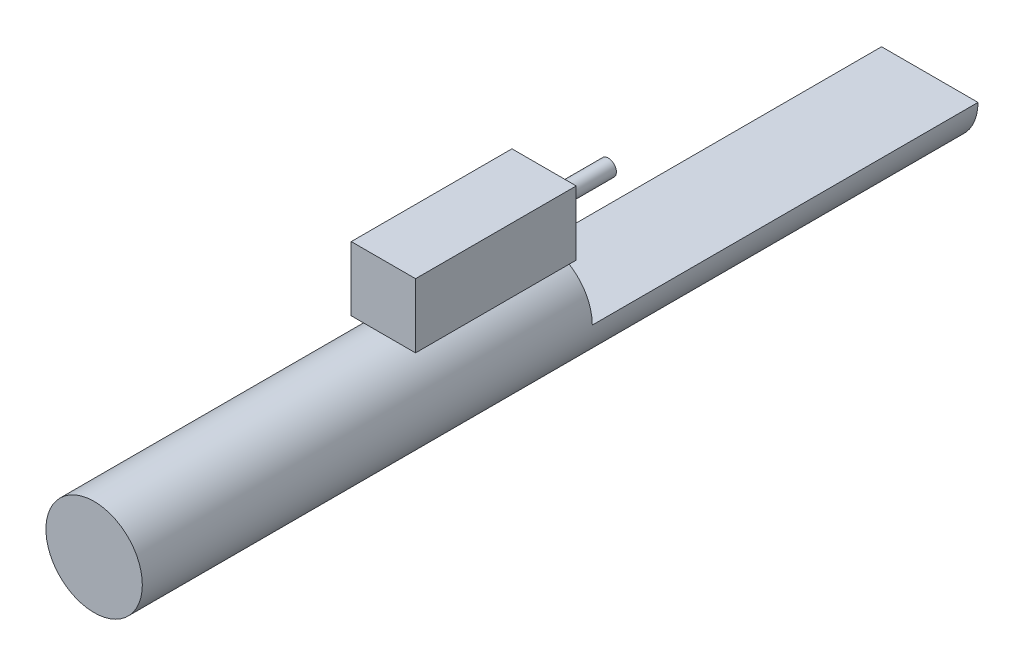
from build123d import *

# Parameters (mm, degrees)
SKETCH_1_R      = 7.5
EXTRUDE_1_DEPTH = 70
EXTRUDE_START   = 60
EXTRUDE_2_DEPTH = 60
SKETCH_4_W      = 10
SKETCH_4_H      = 25
EXTRUDE_3_DEPTH = 10
SKETCH_5_R      = 1.25
EXTRUDE_4_DEPTH = 10


with BuildPart() as part:
    # 草圖1 → 填料-伸長1 (new body)
    with BuildSketch(Plane.XY):
        Circle(SKETCH_1_R)
    extrude(amount=EXTRUDE_1_DEPTH)

    # 草圖2 → 填料-伸長2 (add)
    with BuildSketch(Plane(origin=(0, 0, 0), x_dir=(-1, 0, 0), z_dir=(0, 0, -1)).offset(EXTRUDE_START)):
        with BuildLine():
            Line((-7.5, 0), (7.5, 0))
            ThreePointArc((7.5, 0), (0, -7.5), (-7.5, 0))
        make_face()
    extrude(amount=-EXTRUDE_2_DEPTH)


with BuildPart() as body_2:
    # 草圖4 → 填料-伸長3 (new body)
    with BuildSketch(Plane(origin=(0, 7.5, 0), x_dir=(1, 0, 0), z_dir=(0, 1, 0))):
        with Locations((0, -12.5)):
            Rectangle(SKETCH_4_W, SKETCH_4_H)
    extrude(amount=EXTRUDE_3_DEPTH)

    # 草圖5 → 填料-伸長4 (add)
    with BuildSketch(Plane(origin=(0, 0, 0), x_dir=(-1, 0, 0), z_dir=(0, 0, -1))):
        with Locations((0, 12.5)):
            Circle(SKETCH_5_R)
    extrude(amount=EXTRUDE_4_DEPTH)


solid = Compound([part.part, body_2.part])
